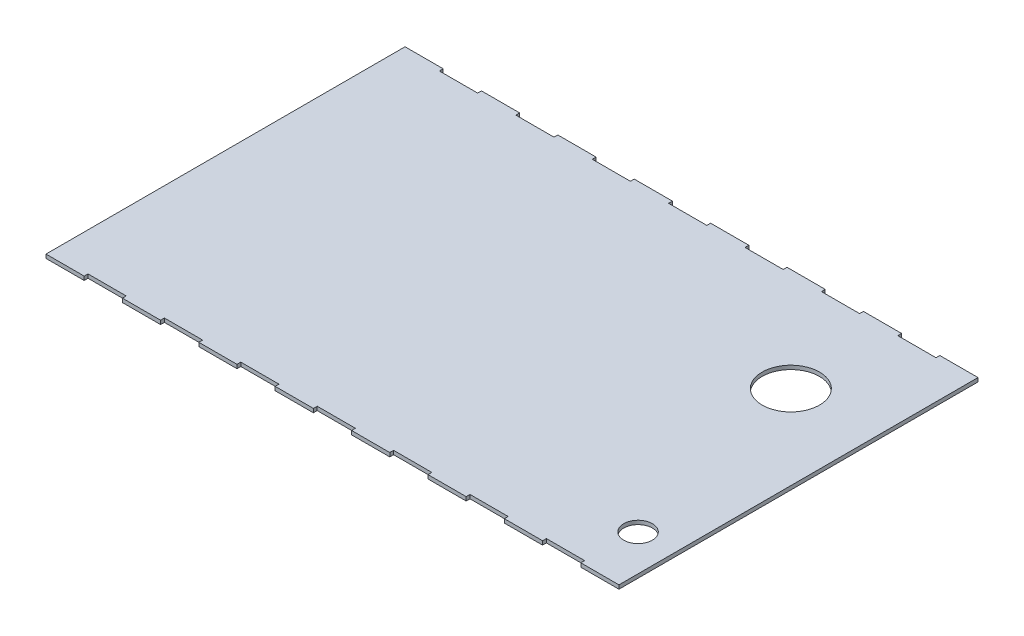
from build123d import *

# Parameters (mm, degrees)
SKETCH1_W               = 300
SKETCH1_H               = 188
BOSS_EXTRUDE1_DEPTH     = 2
SKETCH2_W               = 20
SKETCH2_H               = 2
CUT_EXTRUDE1_DEPTH      = 4
LPATTERN1_COUNT         = 8
LPATTERN1_PITCH         = 40
MIRROR1_COPY_1_SKETCH_W = 20
MIRROR1_COPY_1_SKETCH_H = 2
MIRROR1_COPY_1_DEPTH    = 4
MIRROR1_COPY_2_SKETCH_W = 20
MIRROR1_COPY_2_SKETCH_H = 2
MIRROR1_COPY_2_DEPTH    = 4
MIRROR1_COPY_3_SKETCH_W = 20
MIRROR1_COPY_3_SKETCH_H = 2
MIRROR1_COPY_3_DEPTH    = 4
MIRROR1_COPY_4_SKETCH_W = 20
MIRROR1_COPY_4_SKETCH_H = 2
MIRROR1_COPY_4_DEPTH    = 4
MIRROR1_COPY_5_SKETCH_W = 20
MIRROR1_COPY_5_SKETCH_H = 2
MIRROR1_COPY_5_DEPTH    = 4
MIRROR1_COPY_6_SKETCH_W = 20
MIRROR1_COPY_6_SKETCH_H = 2
MIRROR1_COPY_6_DEPTH    = 4
MIRROR1_COPY_7_SKETCH_W = 20
MIRROR1_COPY_7_SKETCH_H = 2
MIRROR1_COPY_7_DEPTH    = 4
SKETCH4_R               = 7.5
SKETCH4_R_2             = 15
CUT_EXTRUDE2_DEPTH      = 3


with BuildPart() as part:
    # Sketch1 → Boss-Extrude1 (new body)
    with BuildSketch(Plane(origin=(0, 0, 0), x_dir=(1, 0, 0), z_dir=(0, 1, 0))):
        with Locations((-74.28137931, -28.264827586)):
            Rectangle(SKETCH1_W, SKETCH1_H)
    extrude(amount=BOSS_EXTRUDE1_DEPTH)

    # Sketch2 → Cut-Extrude1 (cut)
    with BuildSketch(Plane(origin=(0, 2, 0), x_dir=(1, 0, 0), z_dir=(0, 1, 0))):
        with Locations((-194.28137931, -121.264827586)):
            Rectangle(SKETCH2_W, SKETCH2_H)
    cut_extrude1 = extrude(amount=-CUT_EXTRUDE1_DEPTH, mode=Mode.SUBTRACT)

    # LPattern1: Cut-Extrude1 ×8
    with Locations(*[(i * LPATTERN1_PITCH, 0, 0) for i in range(1, LPATTERN1_COUNT)]):
        add(cut_extrude1, mode=Mode.SUBTRACT)

    # Mirror1: Cut-Extrude1 across plane
    add(cut_extrude1.mirror(Plane.XY.offset(28.264827586)), mode=Mode.SUBTRACT)

    # Mirror1 copy 1 sketch → Mirror1 copy 1 (cut)
    with BuildSketch(Plane(origin=(40, 2, 56.529655172), x_dir=(1, 0, 0), z_dir=(0, 1, 0))):
        with Locations((-194.28137931, 121.264827586)):
            Rectangle(MIRROR1_COPY_1_SKETCH_W, MIRROR1_COPY_1_SKETCH_H)
    extrude(amount=-MIRROR1_COPY_1_DEPTH, mode=Mode.SUBTRACT)

    # Mirror1 copy 2 sketch → Mirror1 copy 2 (cut)
    with BuildSketch(Plane(origin=(80, 2, 56.529655172), x_dir=(1, 0, 0), z_dir=(0, 1, 0))):
        with Locations((-194.28137931, 121.264827586)):
            Rectangle(MIRROR1_COPY_2_SKETCH_W, MIRROR1_COPY_2_SKETCH_H)
    extrude(amount=-MIRROR1_COPY_2_DEPTH, mode=Mode.SUBTRACT)

    # Mirror1 copy 3 sketch → Mirror1 copy 3 (cut)
    with BuildSketch(Plane(origin=(120, 2, 56.529655172), x_dir=(1, 0, 0), z_dir=(0, 1, 0))):
        with Locations((-194.28137931, 121.264827586)):
            Rectangle(MIRROR1_COPY_3_SKETCH_W, MIRROR1_COPY_3_SKETCH_H)
    extrude(amount=-MIRROR1_COPY_3_DEPTH, mode=Mode.SUBTRACT)

    # Mirror1 copy 4 sketch → Mirror1 copy 4 (cut)
    with BuildSketch(Plane(origin=(160, 2, 56.529655172), x_dir=(1, 0, 0), z_dir=(0, 1, 0))):
        with Locations((-194.28137931, 121.264827586)):
            Rectangle(MIRROR1_COPY_4_SKETCH_W, MIRROR1_COPY_4_SKETCH_H)
    extrude(amount=-MIRROR1_COPY_4_DEPTH, mode=Mode.SUBTRACT)

    # Mirror1 copy 5 sketch → Mirror1 copy 5 (cut)
    with BuildSketch(Plane(origin=(200, 2, 56.529655172), x_dir=(1, 0, 0), z_dir=(0, 1, 0))):
        with Locations((-194.28137931, 121.264827586)):
            Rectangle(MIRROR1_COPY_5_SKETCH_W, MIRROR1_COPY_5_SKETCH_H)
    extrude(amount=-MIRROR1_COPY_5_DEPTH, mode=Mode.SUBTRACT)

    # Mirror1 copy 6 sketch → Mirror1 copy 6 (cut)
    with BuildSketch(Plane(origin=(240, 2, 56.529655172), x_dir=(1, 0, 0), z_dir=(0, 1, 0))):
        with Locations((-194.28137931, 121.264827586)):
            Rectangle(MIRROR1_COPY_6_SKETCH_W, MIRROR1_COPY_6_SKETCH_H)
    extrude(amount=-MIRROR1_COPY_6_DEPTH, mode=Mode.SUBTRACT)

    # Mirror1 copy 7 sketch → Mirror1 copy 7 (cut)
    with BuildSketch(Plane(origin=(280, 2, 56.529655172), x_dir=(1, 0, 0), z_dir=(0, 1, 0))):
        with Locations((-194.28137931, 121.264827586)):
            Rectangle(MIRROR1_COPY_7_SKETCH_W, MIRROR1_COPY_7_SKETCH_H)
    extrude(amount=-MIRROR1_COPY_7_DEPTH, mode=Mode.SUBTRACT)

    # Sketch4 → Cut-Extrude2 (cut, through all)
    with BuildSketch(Plane.XZ):
        with Locations((56.71862069, 93.264827586)):
            Circle(SKETCH4_R)
        with Locations((31.71862069, -11.735172414)):
            Circle(SKETCH4_R_2)
    extrude(amount=-CUT_EXTRUDE2_DEPTH, mode=Mode.SUBTRACT)


solid = part.part
